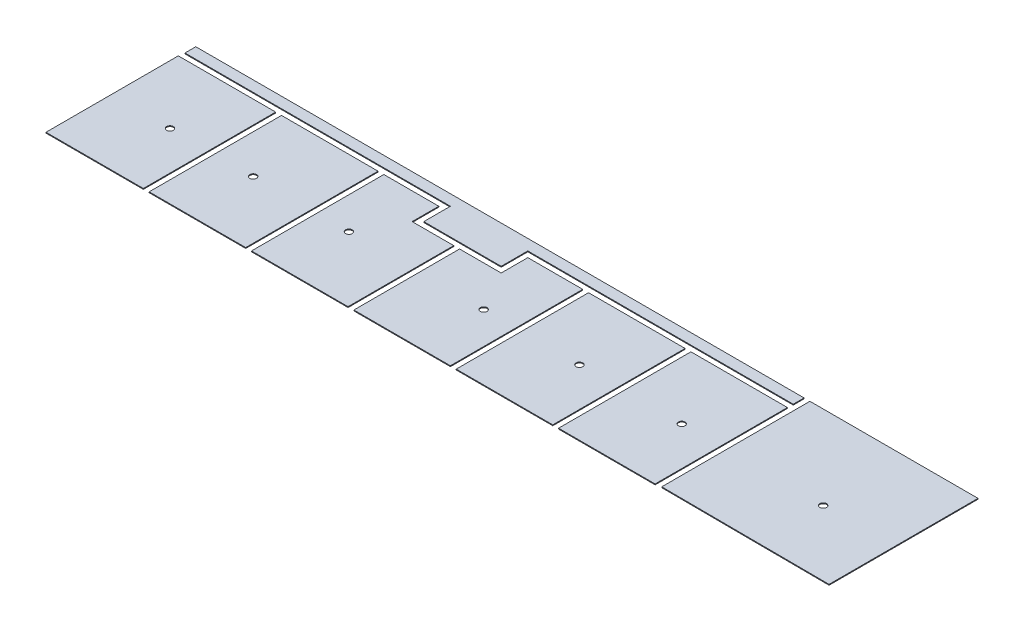
from build123d import *

# Parameters (mm, degrees)
SKETCH1_W             = 1485.9
SKETCH1_H             = 2019.3
BOSS_EXTRUDE1_DEPTH   = 12.7
SKETCH1_W_2           = 1473.2
BOSS_EXTRUDE1_2_DEPTH = 12.7
BOSS_EXTRUDE1_3_DEPTH = 12.7
BOSS_EXTRUDE1_4_DEPTH = 12.7
BOSS_EXTRUDE1_5_DEPTH = 12.7
BOSS_EXTRUDE1_6_DEPTH = 12.7
BOSS_EXTRUDE1_7_DEPTH = 12.7
BOSS_EXTRUDE1_8_DEPTH = 12.7
SKETCH3_R             = 50.8
CUT_EXTRUDE1_DEPTH    = 12.7


with BuildPart() as part:
    # Sketch1 → Boss-Extrude1 (new body)
    with BuildSketch(Plane(origin=(0, 2266.95, 0), x_dir=(1, 0, 0), z_dir=(0, 1, 0))):
        with Locations((781.05, 1047.75)):
            Rectangle(SKETCH1_W, SKETCH1_H)
    extrude(amount=BOSS_EXTRUDE1_DEPTH)


with BuildPart() as body_2:
    # Sketch1 → Boss-Extrude1 2 (new body)
    with BuildSketch(Plane(origin=(0, 2266.95, 0), x_dir=(1, 0, 0), z_dir=(0, 1, 0))):
        with Locations((2349.5, 1047.75)):
            Rectangle(SKETCH1_W_2, SKETCH1_H)
    extrude(amount=BOSS_EXTRUDE1_2_DEPTH)


with BuildPart() as body_3:
    # Sketch1 → Boss-Extrude1 3 (new body)
    with BuildSketch(Plane(origin=(0, 2266.95, 0), x_dir=(1, 0, 0), z_dir=(0, 1, 0))):
        Polygon((4102.1, 2146.3), (50.8, 2146.3), (50.8, 2311.4), (9334.5, 2311.4), (9334.5, 2146.3), (5283.2, 2146.3), (5283.2, 1739.9), (4102.1, 1739.9), align=None)
    extrude(amount=BOSS_EXTRUDE1_3_DEPTH)


with BuildPart() as body_4:
    # Sketch1 → Boss-Extrude1 4 (new body)
    with BuildSketch(Plane(origin=(0, 2266.95, 0), x_dir=(1, 0, 0), z_dir=(0, 1, 0))):
        Polygon((3175, 38.1), (3175, 2057.4), (4013.2, 2057.4), (4013.2, 1651), (4648.2, 1651), (4648.2, 38.1), align=None)
    extrude(amount=BOSS_EXTRUDE1_4_DEPTH)


with BuildPart() as body_5:
    # Sketch1 → Boss-Extrude1 5 (new body)
    with BuildSketch(Plane(origin=(0, 2266.95, 0), x_dir=(1, 0, 0), z_dir=(0, 1, 0))):
        Polygon((5372.1, 2057.4), (5372.1, 1651), (4737.1, 1651), (4737.1, 38.1), (6210.3, 38.1), (6210.3, 2057.4), align=None)
    extrude(amount=BOSS_EXTRUDE1_5_DEPTH)


with BuildPart() as body_6:
    # Sketch1 → Boss-Extrude1 6 (new body)
    with BuildSketch(Plane(origin=(0, 2266.95, 0), x_dir=(1, 0, 0), z_dir=(0, 1, 0))):
        with Locations((7035.8, 1047.75)):
            Rectangle(SKETCH1_W_2, SKETCH1_H)
    extrude(amount=BOSS_EXTRUDE1_6_DEPTH)


with BuildPart() as body_7:
    # Sketch1 → Boss-Extrude1 7 (new body)
    with BuildSketch(Plane(origin=(0, 2266.95, 0), x_dir=(1, 0, 0), z_dir=(0, 1, 0))):
        with Locations((8597.9, 1047.75)):
            Rectangle(SKETCH1_W_2, SKETCH1_H)
    extrude(amount=BOSS_EXTRUDE1_7_DEPTH)


with BuildPart() as body_8:
    # Sketch1 → Boss-Extrude1 8 (new body)
    with BuildSketch(Plane(origin=(0, 2266.95, 0), x_dir=(1, 0, 0), z_dir=(0, 1, 0))):
        Polygon((9423.4, 50.8), (9423.4, 2146.3), (9423.4, 2311.4), (11988.8, 2311.4), (11988.8, 38.1), align=None)
    extrude(amount=BOSS_EXTRUDE1_8_DEPTH)


with BuildPart() as cut_extrude1_tool:
    # Sketch3 → Cut-Extrude1 (new body)
    with BuildSketch(Plane(origin=(0, 2266.95, 0), x_dir=(1, 0, 0), z_dir=(0, 1, 0))):
        with Locations((933.45, 1035.05)):
            Circle(SKETCH3_R)
        with Locations((2203.45, 1035.05)):
            Circle(SKETCH3_R)
        with Locations((5721.35, 1035.05)):
            Circle(SKETCH3_R)
        with Locations((3663.95, 1035.05)):
            Circle(SKETCH3_R)
        with Locations((7181.85, 1035.05)):
            Circle(SKETCH3_R)
        with Locations((8743.95, 1035.05)):
            Circle(SKETCH3_R)
        with Locations((10902.95, 1035.05)):
            Circle(SKETCH3_R)
    extrude(amount=CUT_EXTRUDE1_DEPTH)


with BuildPart() as part_1:
    add(part.part)

    # Cut-Extrude1: cut by cut_extrude1_tool
    add(cut_extrude1_tool.part, mode=Mode.SUBTRACT)


with BuildPart() as body_2_1:
    add(body_2.part)

    # Cut-Extrude1: cut by cut_extrude1_tool
    add(cut_extrude1_tool.part, mode=Mode.SUBTRACT)


with BuildPart() as body_4_1:
    add(body_4.part)

    # Cut-Extrude1: cut by cut_extrude1_tool
    add(cut_extrude1_tool.part, mode=Mode.SUBTRACT)


with BuildPart() as body_5_1:
    add(body_5.part)

    # Cut-Extrude1: cut by cut_extrude1_tool
    add(cut_extrude1_tool.part, mode=Mode.SUBTRACT)


with BuildPart() as body_6_1:
    add(body_6.part)

    # Cut-Extrude1: cut by cut_extrude1_tool
    add(cut_extrude1_tool.part, mode=Mode.SUBTRACT)


with BuildPart() as body_7_1:
    add(body_7.part)

    # Cut-Extrude1: cut by cut_extrude1_tool
    add(cut_extrude1_tool.part, mode=Mode.SUBTRACT)


with BuildPart() as body_8_1:
    add(body_8.part)

    # Cut-Extrude1: cut by cut_extrude1_tool
    add(cut_extrude1_tool.part, mode=Mode.SUBTRACT)


solid = Compound([body_3.part, part_1.part, body_2_1.part, body_4_1.part, body_5_1.part, body_6_1.part, body_7_1.part, body_8_1.part])
